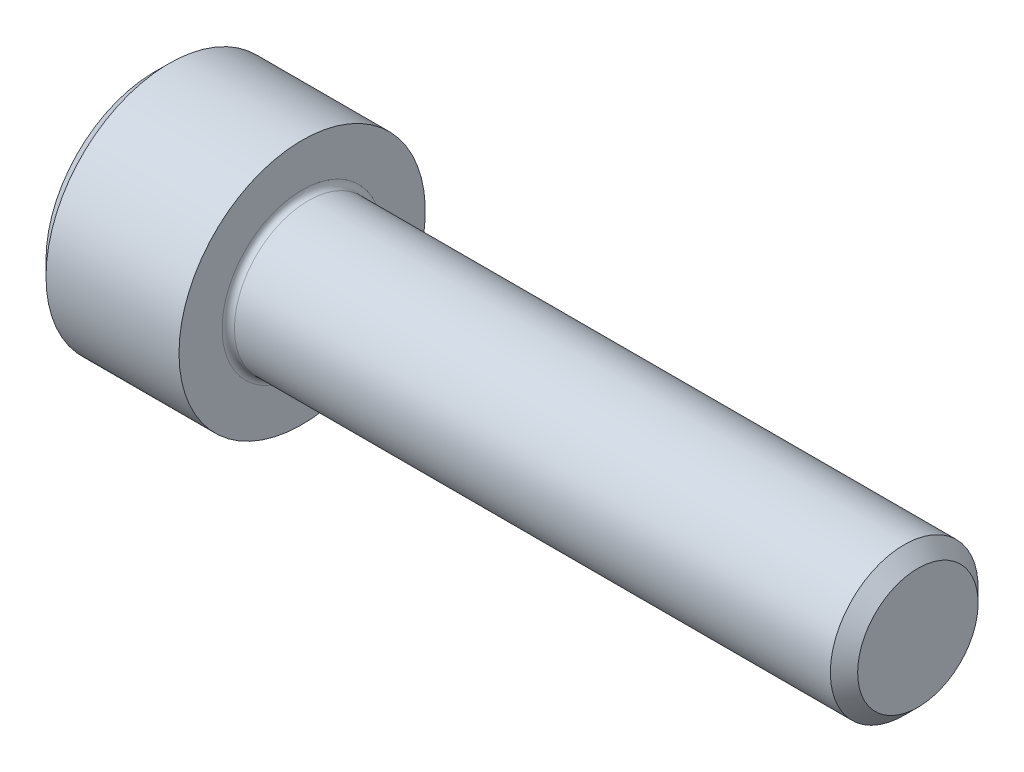
from build123d import *

# Parameters (mm, degrees)
FILLET1_R   = 0.25
HEX_2_DEPTH = 3


with BuildPart() as part:
    # BodySke → Base-Revolve (revolve)
    with BuildSketch(Plane.XY):
        Polygon((0, 0), (0, 4.4), (0.6, 5), (6, 5), (6, 3), (30.4455, 3), (31, 2.4455), (31, 0), align=None)
    revolve(axis=Axis((-31.75, 0, 0), (1, 0, 0)))

    # Fillet1
    fillet1_edges = [part.edges().sort_by_distance(p)[0] for p in [
        (6, -3, 0),
    ]]
    fillet(fillet1_edges, radius=FILLET1_R)

    # Sketch2 → Hex-PreBroach (revolve, cut)
    with BuildSketch(Plane.XY):
        Polygon((0, 2.542), (3, 2.542), (4.467624384, 0), (0, 0), align=None)
    revolve(axis=Axis((0, 0, 0), (1, 0, 0)), mode=Mode.SUBTRACT)

    # Sketch3 → Hex 2 (cut)
    with BuildSketch(Plane(origin=(0, 0, 0), x_dir=(0, 0.5, 0.866025404), z_dir=(-1, 0, 0))):
        Polygon((1.467624384, 2.542), (-1.467624384, 2.542), (-2.935248769, 0), (-1.467624384, -2.542), (1.467624384, -2.542), (2.935248769, 0), align=None)
    extrude(amount=-HEX_2_DEPTH, mode=Mode.SUBTRACT)


solid = part.part
